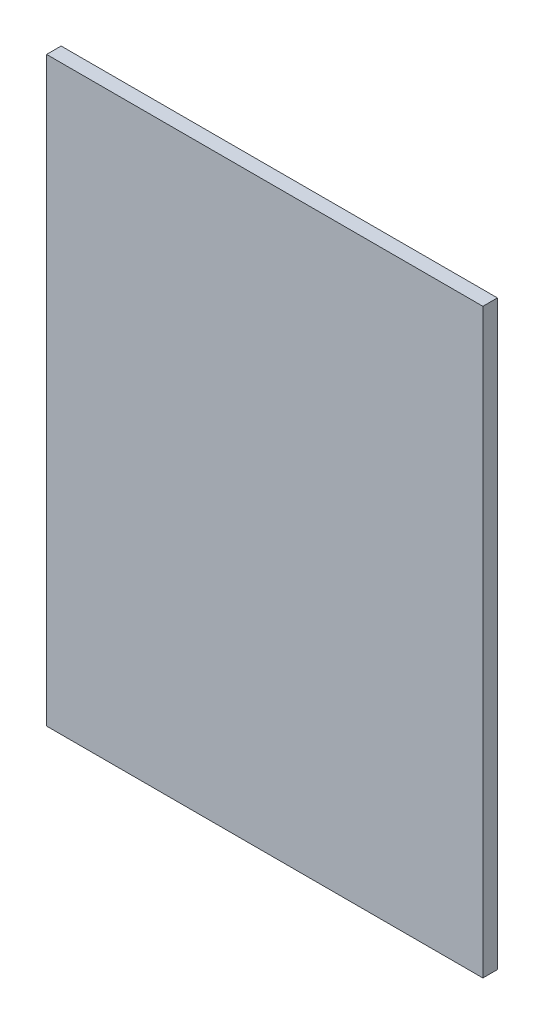
from build123d import *

# Parameters (mm, degrees)
SKETCH1_W      = 300
SKETCH1_H      = 400
EXTRUDE1_DEPTH = 10


with BuildPart() as part:
    # Sketch1 → Extrude1 (new body)
    with BuildSketch(Plane.XY):
        with Locations((150, 200)):
            Rectangle(SKETCH1_W, SKETCH1_H)
    extrude(amount=EXTRUDE1_DEPTH)


solid = part.part
